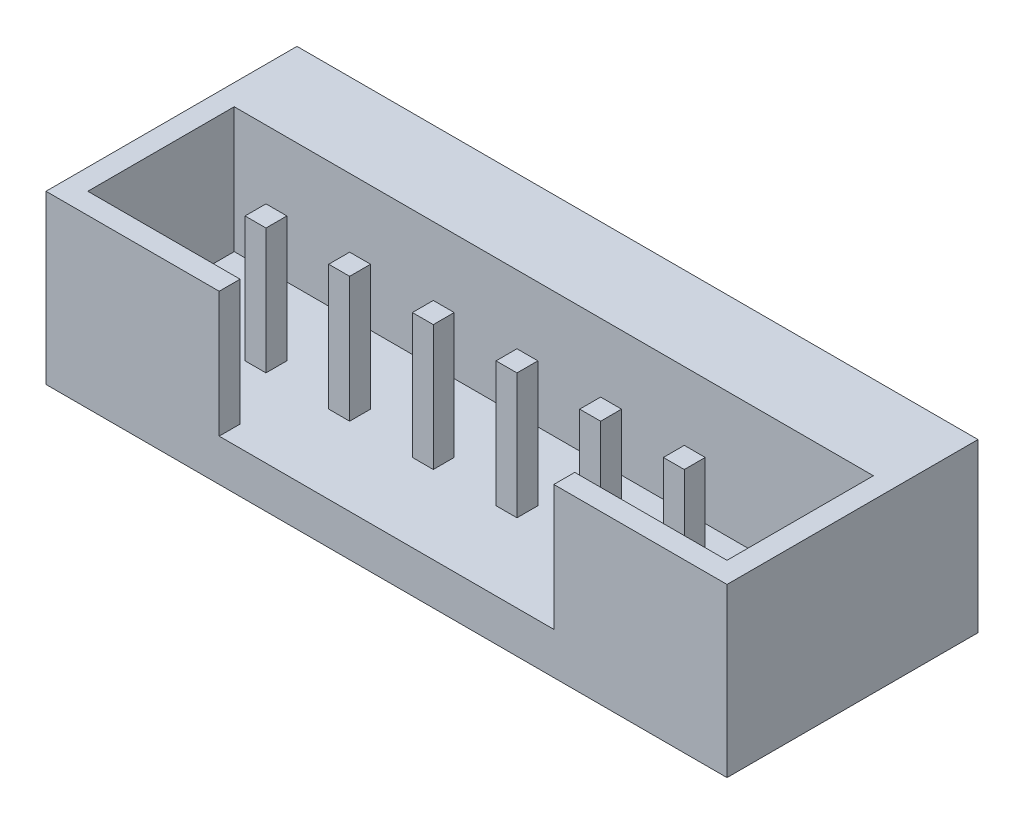
from build123d import *

# Parameters (mm, degrees)
SKETCH1_W           = 16.28
SKETCH1_H           = 6
BOSS_EXTRUDE1_DEPTH = 4
CUT_EXTRUDE1_DEPTH  = 3
SKETCH4_W           = 0.5
SKETCH4_H           = 0.5
BOSS_EXTRUDE2_DEPTH = 3


with BuildPart() as part:
    # Sketch1 → Boss-Extrude1 (new body)
    with BuildSketch(Plane(origin=(0, 0, 0), x_dir=(1, 0, 0), z_dir=(0, 1, 0))):
        Rectangle(SKETCH1_W, SKETCH1_H)
    extrude(amount=BOSS_EXTRUDE1_DEPTH)

    # Sketch2 → Cut-Extrude1 (cut)
    with BuildSketch(Plane(origin=(0, 4, 0), x_dir=(1, 0, 0), z_dir=(0, 1, 0))):
        Polygon((-7.64, -2.5), (-7.64, 1), (7.64, 1), (7.64, -2.5), (4, -2.5), (4, -3), (-4, -3), (-4, -2.5), align=None)
    extrude(amount=-CUT_EXTRUDE1_DEPTH, mode=Mode.SUBTRACT)

    # Sketch4 → Boss-Extrude2 (add)
    with BuildSketch(Plane(origin=(0, 1, 0), x_dir=(1, 0, 0), z_dir=(0, 1, 0))):
        with Locations((-3, -0.881352283)):
            Rectangle(SKETCH4_W, SKETCH4_H)
        with Locations((-5, -0.881352283)):
            Rectangle(SKETCH4_W, SKETCH4_H)
        with Locations((-1, -0.881352283)):
            Rectangle(SKETCH4_W, SKETCH4_H)
        with Locations((1, -0.881352283)):
            Rectangle(SKETCH4_W, SKETCH4_H)
        with Locations((3, -0.881352283)):
            Rectangle(SKETCH4_W, SKETCH4_H)
        with Locations((5, -0.881352283)):
            Rectangle(SKETCH4_W, SKETCH4_H)
    extrude(amount=BOSS_EXTRUDE2_DEPTH)


solid = part.part
